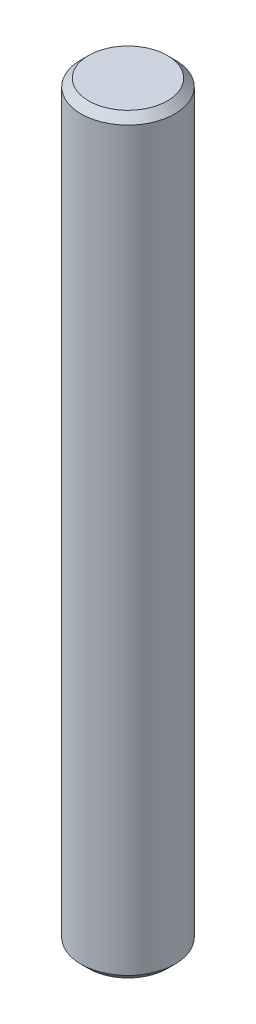
from build123d import *


with BuildPart() as part:
    # Sketch1 → Revolve1 (revolve)
    with BuildSketch(Plane(origin=(0, 0, 0), x_dir=(-1, 0, 0), z_dir=(0, 0, -1))):
        Polygon((-2.66319, 0), (0, 0), (0, 50.8), (-2.66319, 50.8), (-3.17119, 50.292), (-3.17119, 0.508), align=None)
    revolve(axis=Axis((0, 0, 0), (0, 1, 0)))


solid = part.part
